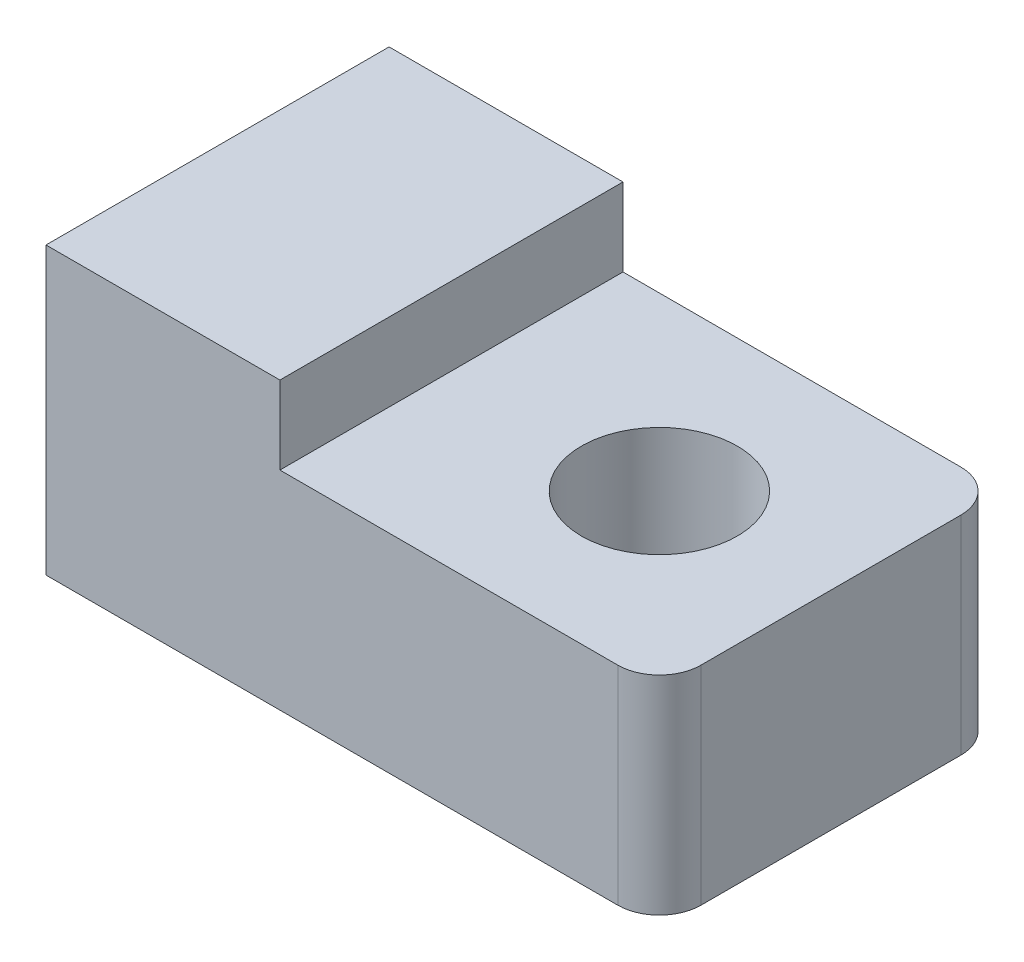
from build123d import *

# Parameters (mm, degrees)
SKETCH1_R           = 1.5
BOSS_EXTRUDE1_DEPTH = 4
SKETCH2_W           = 4.5
SKETCH2_H           = 6.6
BOSS_EXTRUDE2_DEPTH = 1.5


with BuildPart() as part:
    # Sketch1 → Boss-Extrude1 (new body)
    with BuildSketch(Plane(origin=(0, 0, 0), x_dir=(1, 0, 0), z_dir=(0, 1, 0))):
        with BuildLine():
            Line((11.8, -1), (11.8, -6))
            ThreePointArc((11.8, -6), (11.565685425, -6.565685425), (11, -6.8))
            Line((11, -6.8), (0, -6.8))
            Line((0, -6.8), (0, -0.2))
            Line((0, -0.2), (11, -0.2))
            ThreePointArc((11, -0.2), (11.565685425, -0.434314575), (11.8, -1))
        make_face()
        with Locations(Location((8.5, -3.5, 0), (0, 0, 270))):  # turned: the seam where the file's is
            Circle(SKETCH1_R, mode=Mode.SUBTRACT)
    extrude(amount=BOSS_EXTRUDE1_DEPTH)

    # Sketch2 → Boss-Extrude2 (add)
    with BuildSketch(Plane(origin=(0, 4, 0), x_dir=(1, 0, 0), z_dir=(0, 1, 0))):
        with Locations((2.25, -3.5)):
            Rectangle(SKETCH2_W, SKETCH2_H)
    extrude(amount=BOSS_EXTRUDE2_DEPTH)


solid = part.part
